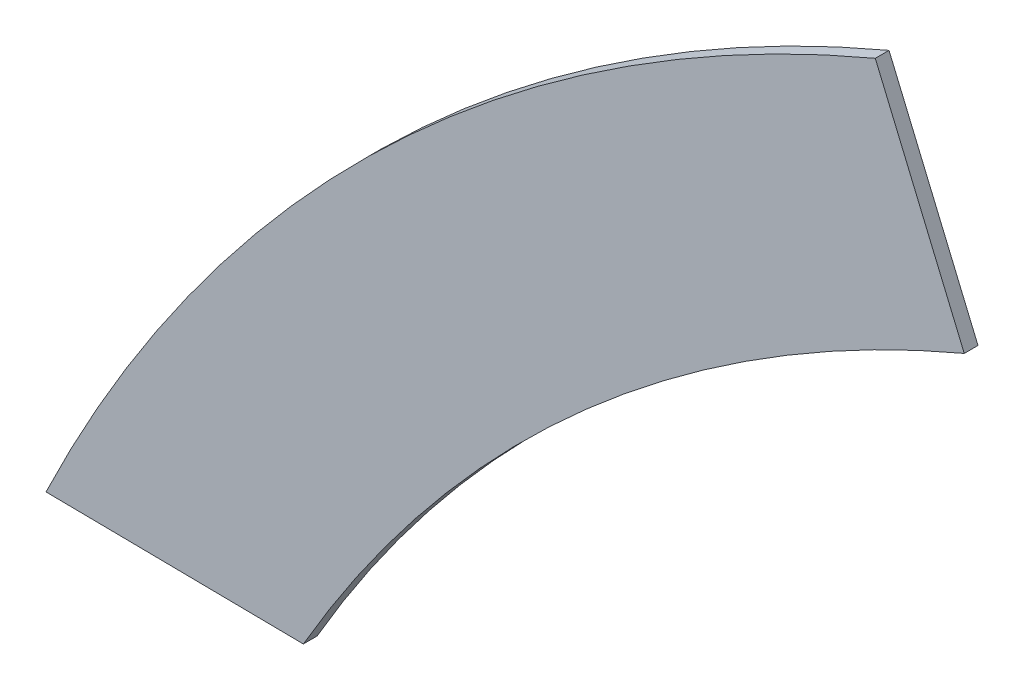
from build123d import *

# Parameters (mm, degrees)
Y_KSEKLIK_EKSTR_ZYON1_DEPTH = 12


with BuildPart() as part:
    # Çizim1 → Yükseklik-Ekstrüzyon1 (new body)
    with BuildSketch(Plane.XY):
        with BuildLine():
            Line((261.716980979, 162.593242631), (184.035913411, 346.890968449))
            ThreePointArc((184.035913411, 346.890968449), (-241.133822738, 68.287890261), (-539.939349276, -342.934965405))
            Line((-539.939349276, -342.934965405), (-315.2766443, -345.583248906))
            ThreePointArc((-315.2766443, -345.583248906), (-68.197330311, -44.46875715), (261.716980979, 162.593242631))
        make_face()
    extrude(amount=Y_KSEKLIK_EKSTR_ZYON1_DEPTH)


solid = part.part
